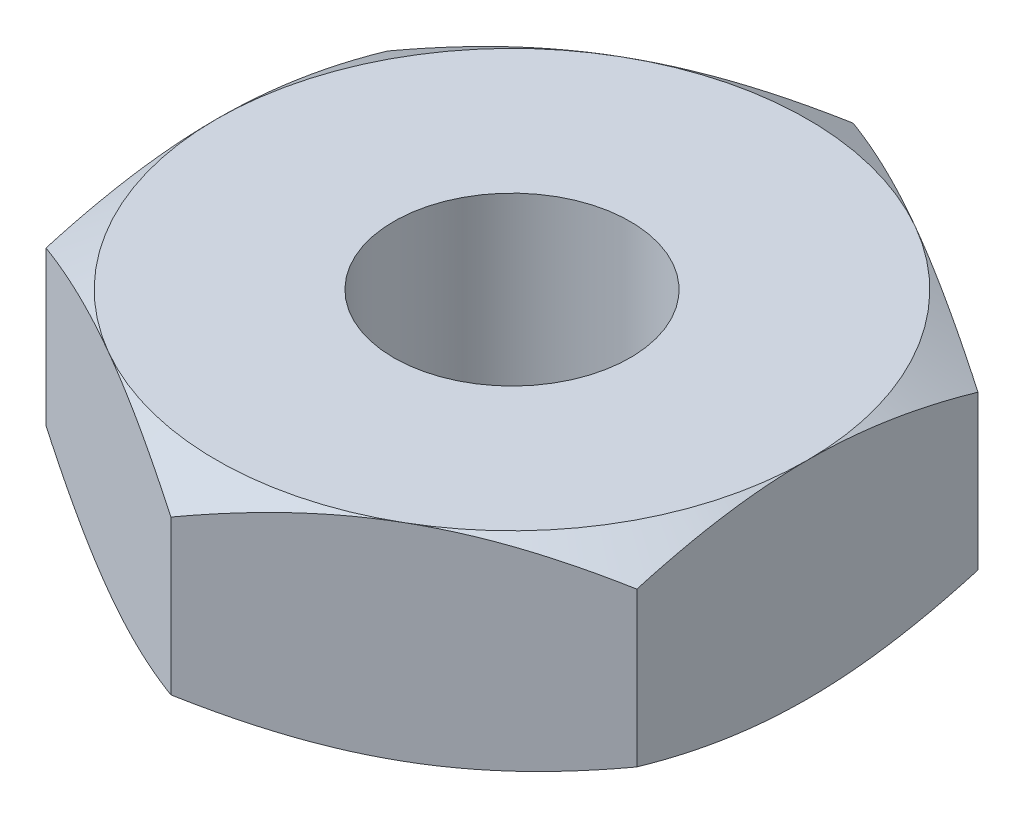
from build123d import *

# Parameters (mm, degrees)
SKETCH1_R               = 1.5875
BOSS_EXTRUDE1_DEPTH     = 1.3890625
SKETCH5_OUTSIDE_W       = 38.99
SKETCH5_OUTSIDE_H       = 40.218
SKETCH5_OUTSIDE_R       = 3.96875
CUT_EXTRUDE2_DEPTH      = 7.668602339
CUT_EXTRUDE2_DRAFT      = -60
MIRROR1_COPY_1_SKETCH_W = 38.99
MIRROR1_COPY_1_SKETCH_H = 40.218
MIRROR1_COPY_1_SKETCH_R = 3.96875
MIRROR1_COPY_1_DEPTH    = 7.668602339
MIRROR1_COPY_1_DRAFT    = -60


with BuildPart() as part:
    # Sketch1 → Boss-Extrude1 (new, symmetric)
    with BuildSketch(Plane(origin=(0, 0, 0), x_dir=(1, 0, 0), z_dir=(0, 1, 0))):
        Polygon((-3.96875, 2.291358881), (-3.96875, -2.291358881), (0, -4.582717762), (3.96875, -2.291358881), (3.96875, 2.291358881), (0, 4.582717762), align=None)
        Circle(SKETCH1_R, mode=Mode.SUBTRACT)
    extrude(amount=BOSS_EXTRUDE1_DEPTH, both=True)


with BuildPart() as cut_extrude2_tool:
    # Sketch5 outside → Cut-Extrude2 (with draft: the straight prism first)
    with BuildSketch(Plane(origin=(0, 1.3890625, 0), x_dir=(1, 0, 0), z_dir=(0, 1, 0))):
        Rectangle(SKETCH5_OUTSIDE_W, SKETCH5_OUTSIDE_H)
        Circle(SKETCH5_OUTSIDE_R, mode=Mode.SUBTRACT)
    extrude(amount=-CUT_EXTRUDE2_DEPTH)
    # Cut-Extrude2: the draft: its side faces are tilted about the plane it starts from
    cut_extrude2_sides = [cut_extrude2_tool.faces().sort_by_distance(p)[0] for p in [
        (0, -2.44523867, 20.109),
        (19.495, -2.44523867, 0),
        (0, -2.44523867, -20.109),
        (-19.495, -2.44523867, 0),
        (-3.96875, -2.44523867, 0),
    ]]
    draft(cut_extrude2_sides, Plane(origin=(0, 1.3890625, 0), x_dir=(1, 0, 0), z_dir=(0, 1, 0)), CUT_EXTRUDE2_DRAFT)


with BuildPart() as part_1:
    add(part.part)

    # Cut-Extrude2: cut by cut_extrude2_tool
    add(cut_extrude2_tool.part, mode=Mode.SUBTRACT)


with BuildPart() as mirror1_copy_1_tool:
    # Mirror1 copy 1 sketch → Mirror1 copy 1 (with draft: the straight prism first)
    with BuildSketch(Plane.XZ.offset(1.3890625)):
        Rectangle(MIRROR1_COPY_1_SKETCH_W, MIRROR1_COPY_1_SKETCH_H)
        Circle(MIRROR1_COPY_1_SKETCH_R, mode=Mode.SUBTRACT)
    extrude(amount=-MIRROR1_COPY_1_DEPTH)
    # Mirror1 copy 1: the draft: its side faces are tilted about the plane it starts from
    mirror1_copy_1_sides = [mirror1_copy_1_tool.faces().sort_by_distance(p)[0] for p in [
        (0, 2.44523867, 20.109),
        (19.495, 2.44523867, 0),
        (0, 2.44523867, -20.109),
        (-19.495, 2.44523867, 0),
        (-3.96875, 2.44523867, 0),
    ]]
    draft(mirror1_copy_1_sides, Plane.XZ.offset(1.3890625), MIRROR1_COPY_1_DRAFT)


with BuildPart() as part_2:
    add(part_1.part)

    # Mirror1 copy 1: cut by mirror1_copy_1_tool
    add(mirror1_copy_1_tool.part, mode=Mode.SUBTRACT)


solid = part_2.part
